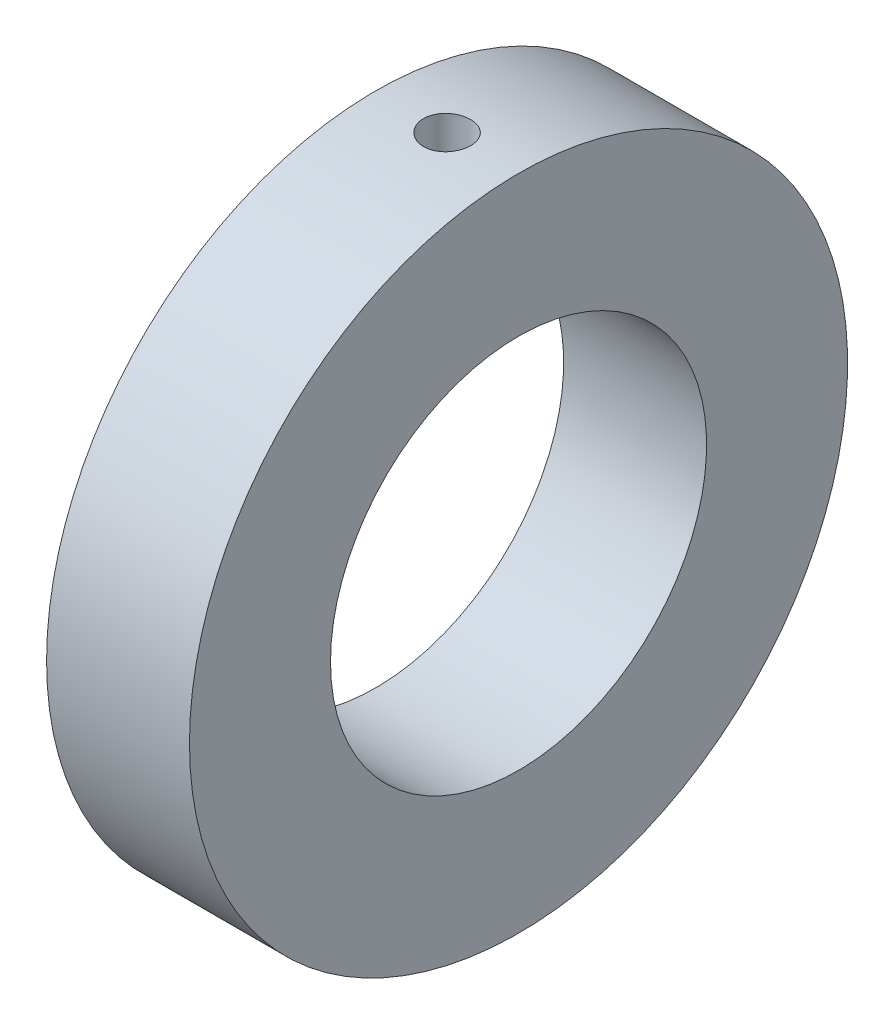
from build123d import *

# Parameters (mm, degrees)
SKETCH1_W                          = 4.826
SKETCH1_H                          = 4.7625
F_1_16_0_0625_DIAMETER_HOLE1_D     = 1.5875
F_1_16_0_0625_DIAMETER_HOLE1_DEPTH = 12.7
F_1_16_0_0625_DIAMETER_HOLE1_TIP   = 0.476933116


with BuildPart() as part:
    # Sketch1 → Revolve1 (revolve)
    with BuildSketch(Plane(origin=(0, 0, 0), x_dir=(1, 0, 0), z_dir=(0, 1, 0))):
        Rectangle(SKETCH1_W, SKETCH1_H)
    revolve(axis=Axis((-13.511198198, 0, -8.73125), (1, 0, 0)))

    # 1/16 (0.0625) Diameter Hole1
    with Locations(Plane(origin=(0, 11.1125, 0), x_dir=(1, 0, 0), z_dir=(0, 1, 0))):
        with Locations((0, 8.73125)):
            Hole(F_1_16_0_0625_DIAMETER_HOLE1_D / 2, depth=F_1_16_0_0625_DIAMETER_HOLE1_DEPTH)
            with Locations((0, 0, -(F_1_16_0_0625_DIAMETER_HOLE1_DEPTH + F_1_16_0_0625_DIAMETER_HOLE1_TIP / 2))):  # 118° drill point
                Cone(0, F_1_16_0_0625_DIAMETER_HOLE1_D / 2, F_1_16_0_0625_DIAMETER_HOLE1_TIP, mode=Mode.SUBTRACT)


solid = part.part
